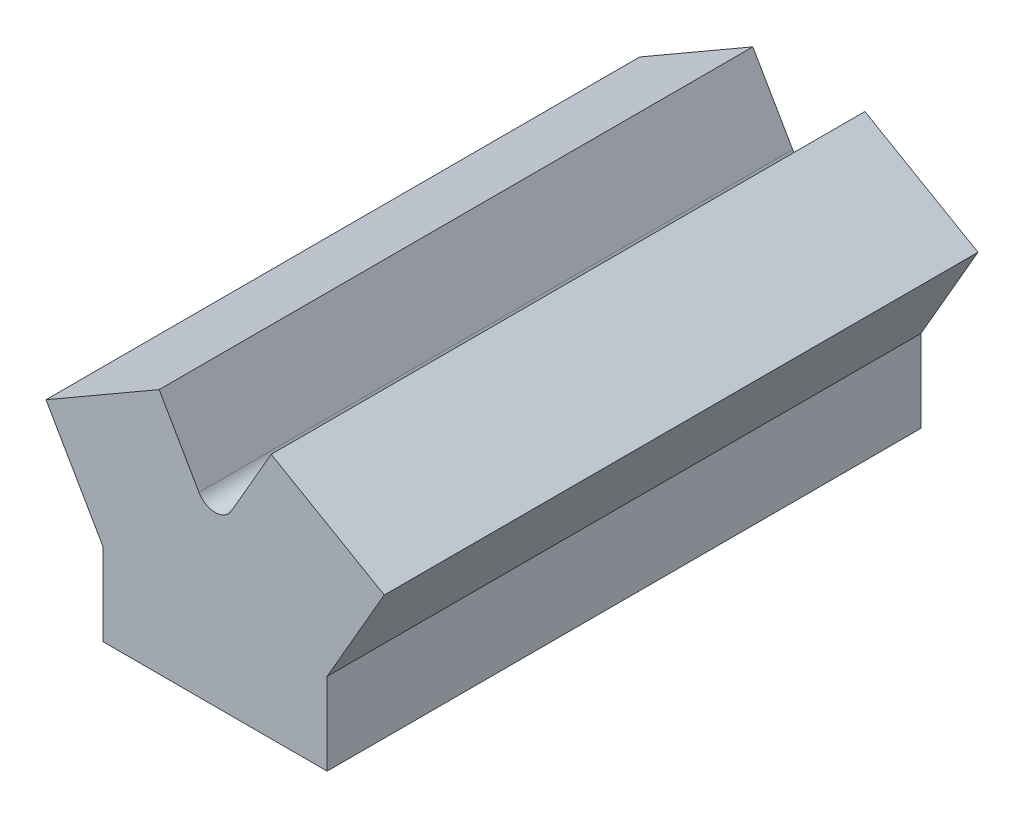
from build123d import *

# Parameters (mm, degrees)
BOSS_EXTRUDE1_DEPTH = 403.86
CUT_EXTRUDE1_START  = -19.05
SKETCH3_R           = 22.86
CUT_EXTRUDE1_DEPTH  = 203.697116111
CUT_EXTRUDE2_START  = -19.05
SKETCH4_R           = 22.86
CUT_EXTRUDE2_DEPTH  = 203.697116111
CUT_EXTRUDE4_START  = -25.4
CUT_EXTRUDE4_DEPTH  = 353.06
SKETCH7_R           = 6.35
CUT_EXTRUDE5_DEPTH  = 76.2


with BuildPart() as part:
    # Sketch1 → Boss-Extrude1 (new body)
    with BuildSketch(Plane.XY):
        with BuildLine():
            Line((-10.998522628, 120.65), (-38.114105889, 167.615567884))
            Line((-38.114105889, 167.615567884), (-115.061446619, 123.19))
            Line((-115.061446619, 123.19), (-76.2, 55.88))
            Line((-76.2, 55.88), (-76.2, 0))
            Line((-76.2, 0), (76.2, 0))
            Line((76.2, 0), (76.2, 55.88))
            Line((76.2, 55.88), (115.061446619, 123.19))
            Line((115.061446619, 123.19), (38.114105889, 167.615567884))
            Line((38.114105889, 167.615567884), (10.998522628, 120.65))
            ThreePointArc((10.998522628, 120.65), (0, 114.3), (-10.998522628, 120.65))
        make_face()
    extrude(amount=-BOSS_EXTRUDE1_DEPTH)

    # Sketch3 → Cut-Extrude1 (cut, through all)
    with BuildSketch(Plane(origin=(82.108196401, 142.215567884, 0), x_dir=(0.866025404, -0.5, 0), z_dir=(0.5, 0.866025404, 0)).offset(CUT_EXTRUDE1_START)):
        with Locations((-6.374432116, 119.38)):
            Circle(SKETCH3_R)
        with Locations((-6.374432116, 231.14)):
            Circle(SKETCH3_R)
        with Locations((-6.374432116, 342.9)):
            Circle(SKETCH3_R)
    extrude(amount=-CUT_EXTRUDE1_DEPTH, mode=Mode.SUBTRACT)

    # Sketch4 → Cut-Extrude2 (cut, through all)
    with BuildSketch(Plane(origin=(-82.108196401, 142.215567884, 0), x_dir=(0.866025404, 0.5, 0), z_dir=(-0.5, 0.866025404, 0)).offset(CUT_EXTRUDE2_START)):
        with Locations((6.374432116, 63.5)):
            Circle(SKETCH4_R)
        with Locations((6.374432116, 175.26)):
            Circle(SKETCH4_R)
        with Locations((6.374432116, 287.02)):
            Circle(SKETCH4_R)
    extrude(amount=-CUT_EXTRUDE2_DEPTH, mode=Mode.SUBTRACT)

    # Sketch5 → Cut-Extrude4 (cut)
    with BuildSketch(Plane.XY.offset(CUT_EXTRUDE4_START)):
        with BuildLine():
            Line((-50.8, 0), (-50.8, 31.75))
            Line((-50.8, 31.75), (-26.311519178, 45.814017315))
            ThreePointArc((-26.311519178, 45.814017315), (0, 52.832), (26.311519178, 45.814017315))
            Line((26.311519178, 45.814017315), (50.8, 31.75))
            Line((50.8, 31.75), (50.8, 0))
            Line((50.8, 0), (-50.8, 0))
        make_face()
    extrude(amount=-CUT_EXTRUDE4_DEPTH, mode=Mode.SUBTRACT)

    # Sketch7 → Cut-Extrude5 (cut)
    with BuildSketch(Plane.XZ):
        with Locations((-63.5, -391.16)):
            Circle(SKETCH7_R)
        with Locations((63.5, -12.7)):
            Circle(SKETCH7_R)
    extrude(amount=-CUT_EXTRUDE5_DEPTH, mode=Mode.SUBTRACT)


solid = part.part
